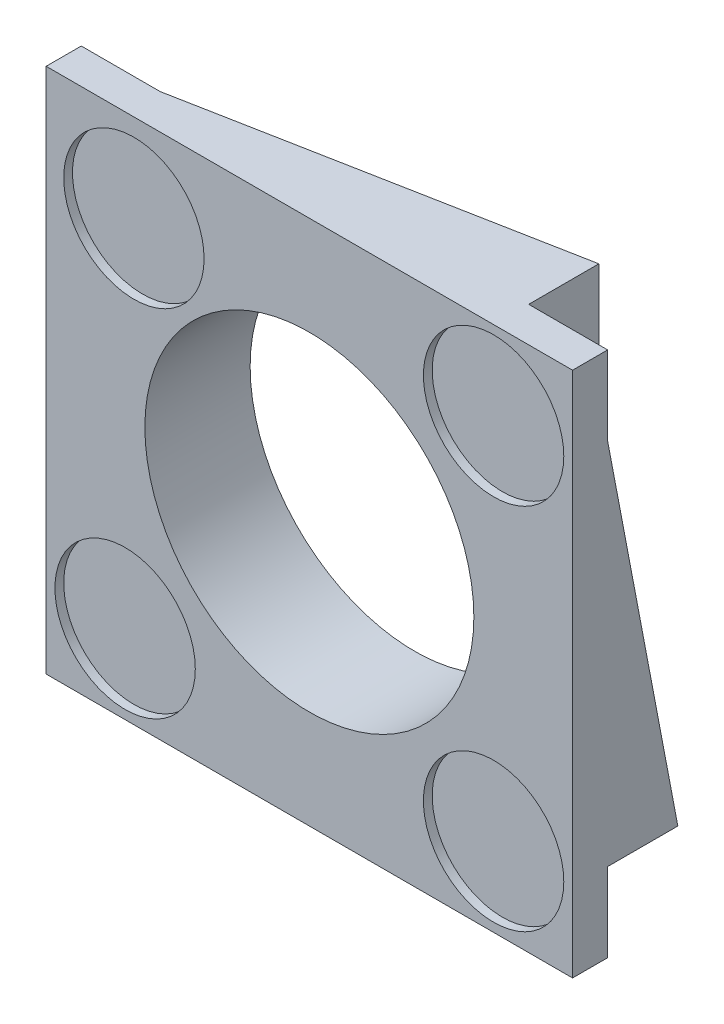
from build123d import *

# Parameters (mm, degrees)
CROQUIS1_W              = 600
CROQUIS1_H              = 600
CROQUIS1_R              = 187.5
SALIENTE_EXTRUIR1_DEPTH = 120
CROQUIS3_W              = 80
CROQUIS3_H              = 90
CORTAR_EXTRUIR2_DEPTH   = 80
CROQUIS5_W              = 80
CROQUIS5_H              = 90
CORTAR_EXTRUIR3_DEPTH   = 90
CORTAR_EXTRUIR4_DEPTH   = 80
CROQUIS7_W              = 89.245379234
CROQUIS7_H              = 80
CORTAR_EXTRUIR5_DEPTH   = 90
CORTAR_EXTRUIR13_DEPTH  = 80
CROQUIS10_W             = 90
CROQUIS10_H             = 80
CORTAR_EXTRUIR15_DEPTH  = 90
CORTAR_EXTRUIR17_DEPTH  = 80
CROQUIS12_W             = 80
CROQUIS12_H             = 90
CORTAR_EXTRUIR19_DEPTH  = 90
CROQUIS13_R             = 80
CORTAR_EXTRUIR20_DEPTH  = 10
CROQUIS14_R             = 80
CORTAR_EXTRUIR21_DEPTH  = 10


with BuildPart() as part:
    # Croquis1 → Saliente-Extruir1 (new body)
    with BuildSketch(Plane.XY):
        Rectangle(CROQUIS1_W, CROQUIS1_H)
        Circle(CROQUIS1_R, mode=Mode.SUBTRACT)
    extrude(amount=SALIENTE_EXTRUIR1_DEPTH)

    # Croquis3 → Cortar-Extruir2 (cut)
    with BuildSketch(Plane.ZY.offset(300)):
        Polygon((0, 210), (0, -210), (80, -210), align=None)
        with Locations((40, 255)):
            Rectangle(CROQUIS3_W, CROQUIS3_H)
    extrude(amount=-CORTAR_EXTRUIR2_DEPTH, mode=Mode.SUBTRACT)

    # Croquis5 → Cortar-Extruir3 (cut)
    with BuildSketch(Plane.ZY.offset(300)):
        with Locations((40, -255)):
            Rectangle(CROQUIS5_W, CROQUIS5_H)
    extrude(amount=-CORTAR_EXTRUIR3_DEPTH, mode=Mode.SUBTRACT)

    # Croquis6 → Cortar-Extruir4 (cut)
    with BuildSketch(Plane(origin=(0, 300, 0), x_dir=(1, 0, 0), z_dir=(0, 1, 0))):
        Polygon((-210, -80), (210, 0), (-210, 0), align=None)
    extrude(amount=-CORTAR_EXTRUIR4_DEPTH, mode=Mode.SUBTRACT)

    # Croquis7 → Cortar-Extruir5 (cut)
    with BuildSketch(Plane(origin=(0, 300, 0), x_dir=(1, 0, 0), z_dir=(0, 1, 0))):
        with Locations((-254.622689617, -40)):
            Rectangle(CROQUIS7_W, CROQUIS7_H)
    extrude(amount=-CORTAR_EXTRUIR5_DEPTH, mode=Mode.SUBTRACT)

    # Croquis8 → Cortar-Extruir13 (cut)
    with BuildSketch(Plane(origin=(300, 0, 0), x_dir=(0, 0, -1), z_dir=(1, 0, 0))):
        Polygon((-80, 210), (0, -210), (0, 210), align=None)
    extrude(amount=-CORTAR_EXTRUIR13_DEPTH, mode=Mode.SUBTRACT)

    # Croquis10 → Cortar-Extruir15 (cut)
    with BuildSketch(Plane(origin=(0, 300, 0), x_dir=(1, 0, 0), z_dir=(0, 1, 0))):
        with Locations((255, -40)):
            Rectangle(CROQUIS10_W, CROQUIS10_H)
    extrude(amount=-CORTAR_EXTRUIR15_DEPTH, mode=Mode.SUBTRACT)

    # Croquis11 → Cortar-Extruir17 (cut)
    with BuildSketch(Plane.XZ.offset(300)):
        Polygon((210, 80), (-210, 0), (210, 0), align=None)
    extrude(amount=-CORTAR_EXTRUIR17_DEPTH, mode=Mode.SUBTRACT)

    # Croquis12 → Cortar-Extruir19 (cut)
    with BuildSketch(Plane(origin=(300, 0, 0), x_dir=(0, 0, -1), z_dir=(1, 0, 0))):
        with Locations((-40, -255)):
            Rectangle(CROQUIS12_W, CROQUIS12_H)
    extrude(amount=-CORTAR_EXTRUIR19_DEPTH, mode=Mode.SUBTRACT)

    # Croquis13 → Cortar-Extruir20 (cut)
    with BuildSketch(Plane.XY.offset(120)):
        with Locations((-200, 200)):
            Circle(CROQUIS13_R)
    extrude(amount=-CORTAR_EXTRUIR20_DEPTH, mode=Mode.SUBTRACT)

    # Croquis14 → Cortar-Extruir21 (cut)
    with BuildSketch(Plane.XY.offset(120)):
        with Locations((-210, -210)):
            Circle(CROQUIS14_R)
        with Locations((210, -210)):
            Circle(CROQUIS14_R)
        with Locations((210, 210)):
            Circle(CROQUIS14_R)
    extrude(amount=-CORTAR_EXTRUIR21_DEPTH, mode=Mode.SUBTRACT)


solid = part.part
